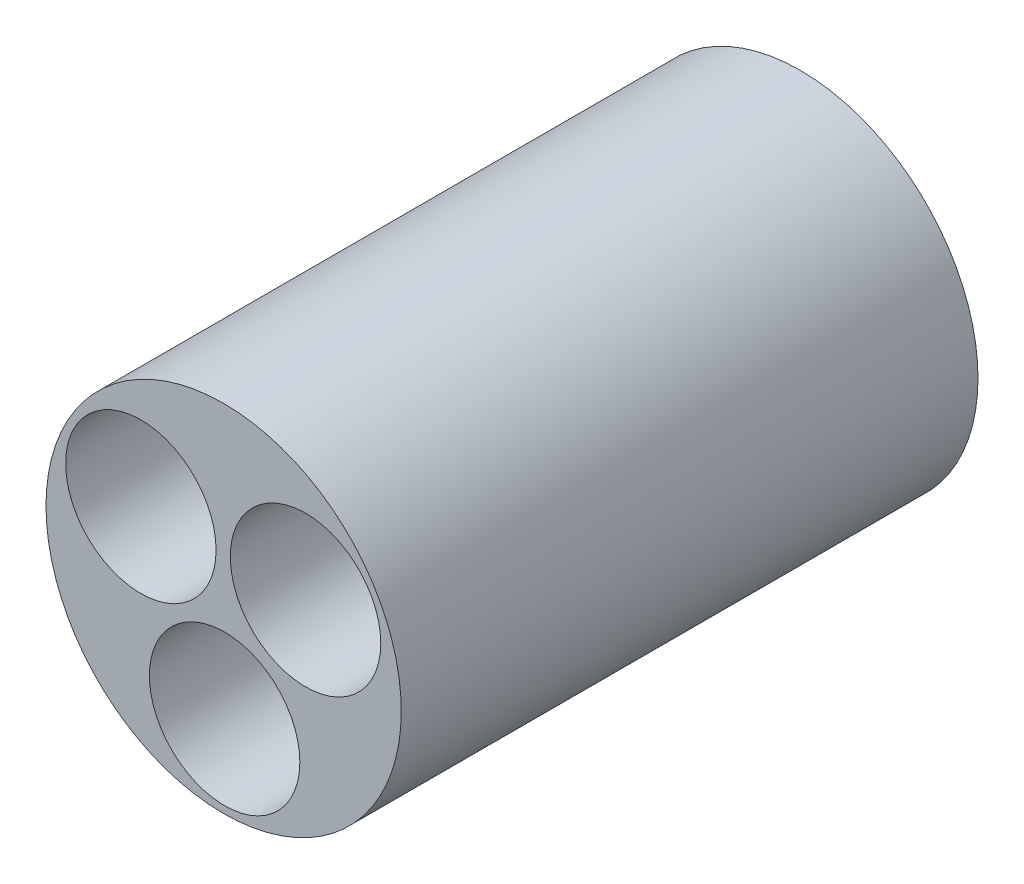
from build123d import *

# Parameters (mm, degrees)
SKETCH1_R           = 21.59
SKETCH1_R_2         = 9.144
BOSS_EXTRUDE1_DEPTH = 70.1


with BuildPart() as part:
    # Sketch1 → Boss-Extrude1 (new body)
    with BuildSketch(Plane.XY):
        Circle(SKETCH1_R)
        with Locations((0.118855304, -11.557)):
            Circle(SKETCH1_R_2, mode=Mode.SUBTRACT)
        with Locations((9.955579479, 5.869470694)):
            Circle(SKETCH1_R_2, mode=Mode.SUBTRACT)
        with Locations((-10.060900468, 5.687049391)):
            Circle(SKETCH1_R_2, mode=Mode.SUBTRACT)
    extrude(amount=BOSS_EXTRUDE1_DEPTH)


solid = part.part
